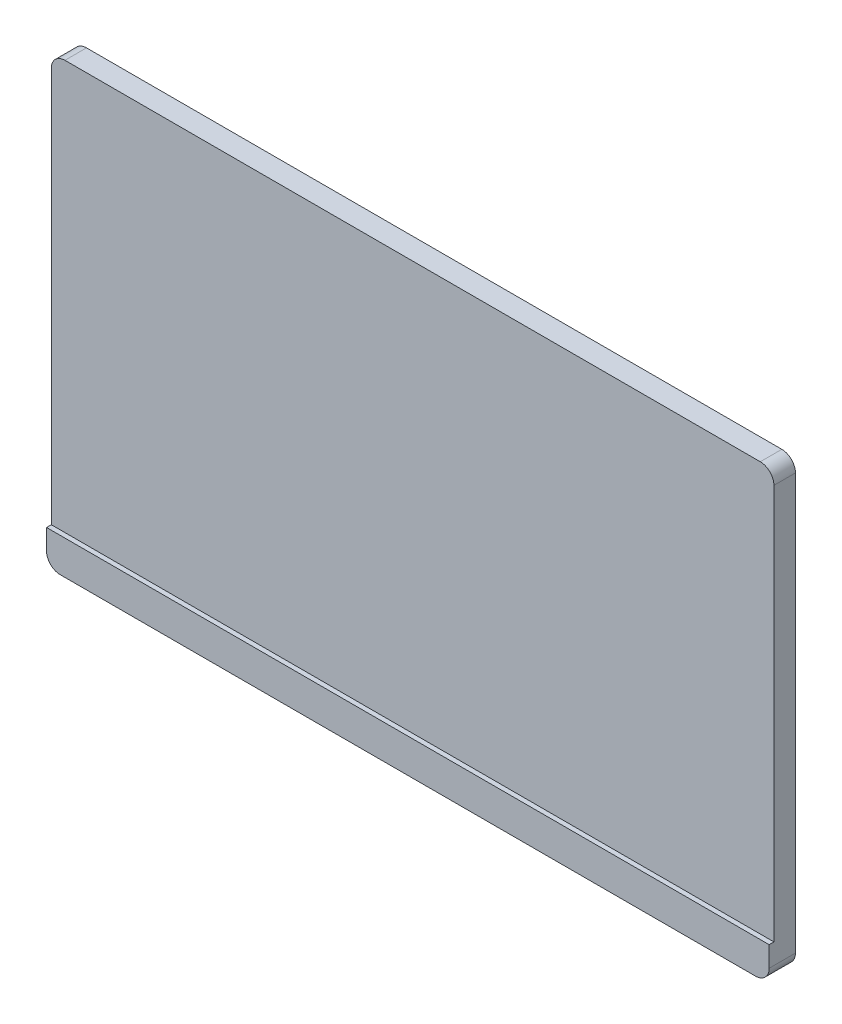
from build123d import *

# Parameters (mm, degrees)
ESBO_O1_W                = 530
ESBO_O1_H                = 325
RESSALTO_EXTRUS_O1_DEPTH = 15.8
ESBO_O2_W                = 530
ESBO_O2_H                = 25
RESSALTO_EXTRUS_O2_DEPTH = 3.5
ESBO_O3_W                = 530
ESBO_O3_H                = 220
RESSALTO_EXTRUS_O3_DEPTH = 30
CORTE_EXTRUS_O1_DEPTH    = 221
CORTE_EXTRUS_O2_DEPTH    = 221
FILETE2_R                = 10


with BuildPart() as part:
    # Esboço1 → Ressalto-extrusão1 (new body)
    with BuildSketch(Plane.XY):
        with Locations((265, 162.5)):
            Rectangle(ESBO_O1_W, ESBO_O1_H)
    extrude(amount=RESSALTO_EXTRUS_O1_DEPTH)

    # Esboço2 → Ressalto-extrusão2 (add)
    with BuildSketch(Plane.XY.offset(15.8)):
        with Locations((265, 12.5)):
            Rectangle(ESBO_O2_W, ESBO_O2_H)
    extrude(amount=RESSALTO_EXTRUS_O2_DEPTH)

    # Esboço3 → Ressalto-extrusão3 (add)
    with BuildSketch(Plane(origin=(0, 0, 0), x_dir=(-1, 0, 0), z_dir=(0, 0, -1))):
        with Locations((-265, 110)):
            Rectangle(ESBO_O3_W, ESBO_O3_H)
    extrude(amount=RESSALTO_EXTRUS_O3_DEPTH)

    # Esboço4 → Corte-extrusão1 (cut, through all)
    with BuildSketch(Plane(origin=(0, 220, 0), x_dir=(1, 0, 0), z_dir=(0, 1, 0))):
        with BuildLine():
            Line((530, 0), (530, 30))
            Line((530, 30), (420, 30))
            ThreePointArc((420, 30), (448.437782273, 25.577393935), (475, 14.499691353))
            ThreePointArc((475, 14.499691353), (501.560410299, 3.685808879), (530, 0))
        make_face()
    extrude(amount=-CORTE_EXTRUS_O1_DEPTH, mode=Mode.SUBTRACT)

    # Esboço6 → Corte-extrusão2 (cut, through all)
    with BuildSketch(Plane(origin=(0, 220, 0), x_dir=(1, 0, 0), z_dir=(0, 1, 0))):
        with BuildLine():
            Line((0, 0), (0, 30))
            Line((0, 30), (110, 30))
            ThreePointArc((110, 30), (81.495614373, 26.182747301), (55, 15))
            ThreePointArc((55, 15), (28.504385627, 3.817252699), (0, 0))
        make_face()
    extrude(amount=-CORTE_EXTRUS_O2_DEPTH, mode=Mode.SUBTRACT)

    # Filete2
    filete2_edges = [part.edges().sort_by_distance(p)[0] for p in [
        (0, 325, 7.9),
        (530, 325, 7.9),
        (530, 0, 9.65),
        (0, 0, 9.65),
    ]]
    fillet(filete2_edges, radius=FILETE2_R)


solid = part.part
